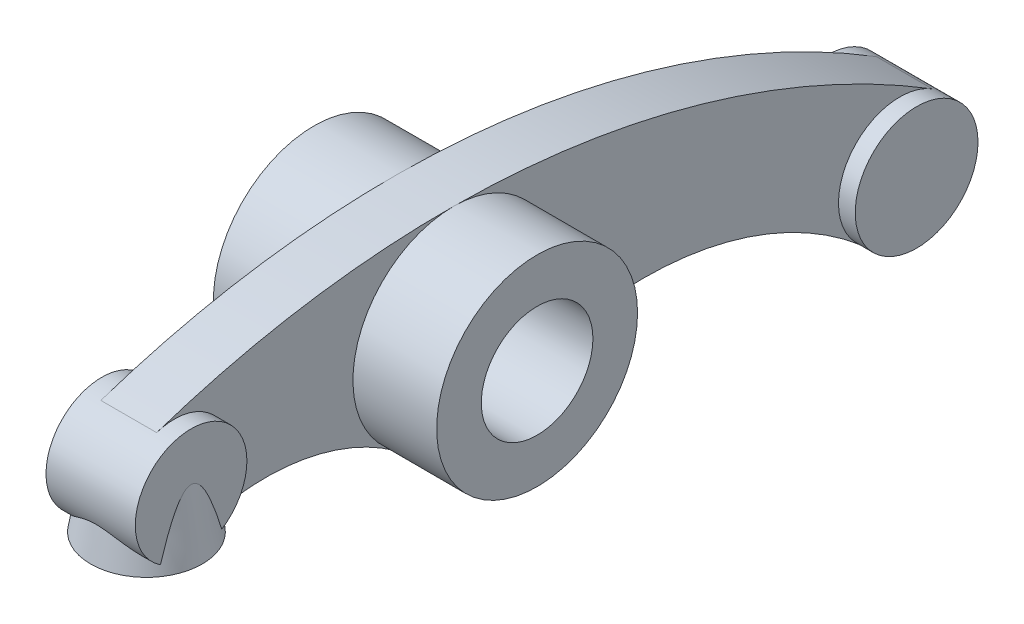
from build123d import *

# Parameters (mm, degrees)
SKETCH1_R             = 5
BOSS_EXTRUDE1_DEPTH   = 4
SKETCH1_R_2           = 5.5
BOSS_EXTRUDE1_2_DEPTH = 4
BOSS_EXTRUDE2_DEPTH   = 2.5
SKETCH1_5_R           = 5
BOSS_EXTRUDE3_DEPTH   = 10
SKETCH2_R             = 5
BOSS_EXTRUDE4_DEPTH   = 6
BOSS_EXTRUDE4_TAPER   = 10


with BuildPart() as part:
    # Sketch1 → Boss-Extrude1 (new, symmetric)
    with BuildSketch(Plane(origin=(0, 0, 0), x_dir=(0, 0, -1), z_dir=(1, 0, 0))):
        with Locations((-25, 0)):
            Circle(SKETCH1_R)
    extrude(amount=BOSS_EXTRUDE1_DEPTH, both=True)



with BuildPart() as body_2:
    # Sketch1 → Boss-Extrude1 2 (new, symmetric)
    with BuildSketch(Plane(origin=(0, 0, 0), x_dir=(0, 0, -1), z_dir=(1, 0, 0))):
        with Locations((40, -8)):
            Circle(SKETCH1_R_2)
    extrude(amount=BOSS_EXTRUDE1_2_DEPTH, both=True)


with BuildPart() as part_1:
    add(part.part)

    add(body_2.part)  # Boss-Extrude2 merges body 2
    # Sketch1_4 → Boss-Extrude2 (add, symmetric)
    with BuildSketch(Plane(origin=(0, 0, 0), x_dir=(0, 0, -1), z_dir=(1, 0, 0))):
        with BuildLine():
            ThreePointArc((-23.364, -4.72477555), (-13.975777786, -3.827150749), (-5.22, -7.331548268))
            ThreePointArc((-5.22, -7.331548268), (-8.564434584, 2.765946539), (0.054339506, 8.999835955))
            ThreePointArc((0.054339506, 8.999835955), (-13.442029091, 7.968983561), (-26.587261688, 4.741371145))
            ThreePointArc((-26.587261688, 4.741371145), (-20.266863918, 1.611652205), (-23.364, -4.72477555))
        make_face()
        with BuildLine():
            ThreePointArc((0.054339506, 8.999835955), (8.776905386, 1.99146475), (3.93314704, -8.09508211))
            ThreePointArc((3.93314704, -8.09508211), (20.797515441, -5.314475766), (36.443380407, -12.195289867))
            ThreePointArc((36.443380407, -12.195289867), (35.551534206, -4.76562957), (42.894164623, -3.323055363))
            ThreePointArc((42.894164623, -3.323055363), (22.323850565, 5.791970771), (0.054339506, 8.999835955))
        make_face()
    extrude(amount=BOSS_EXTRUDE2_DEPTH, both=True)

    # Sketch1_5 → Boss-Extrude3 (add, symmetric)
    with BuildSketch(Plane(origin=(0, 0, 0), x_dir=(0, 0, -1), z_dir=(1, 0, 0))):
        with BuildLine():
            ThreePointArc((0.054339506, 8.999835955), (-8.564434584, 2.765946539), (-5.22, -7.331548268))
            ThreePointArc((-5.22, -7.331548268), (-0.748160155, -8.968849223), (3.93314704, -8.09508211))
            ThreePointArc((3.93314704, -8.09508211), (7.628837505, -4.775022337), (9, 0))
            ThreePointArc((9, 0), (6.383144035, 6.344720027), (0.054339506, 8.999835955))
        make_face()
        Circle(SKETCH1_5_R, mode=Mode.SUBTRACT)
    extrude(amount=BOSS_EXTRUDE3_DEPTH, both=True)

    # Sketch2 → Boss-Extrude4 (add)
    with BuildSketch(Plane(origin=(0, -5, 0), x_dir=(1, 0, 0), z_dir=(0, 1, 0))):
        with Locations((0, -25)):
            Circle(SKETCH2_R)
    extrude(amount=BOSS_EXTRUDE4_DEPTH, taper=BOSS_EXTRUDE4_TAPER)


solid = part_1.part
